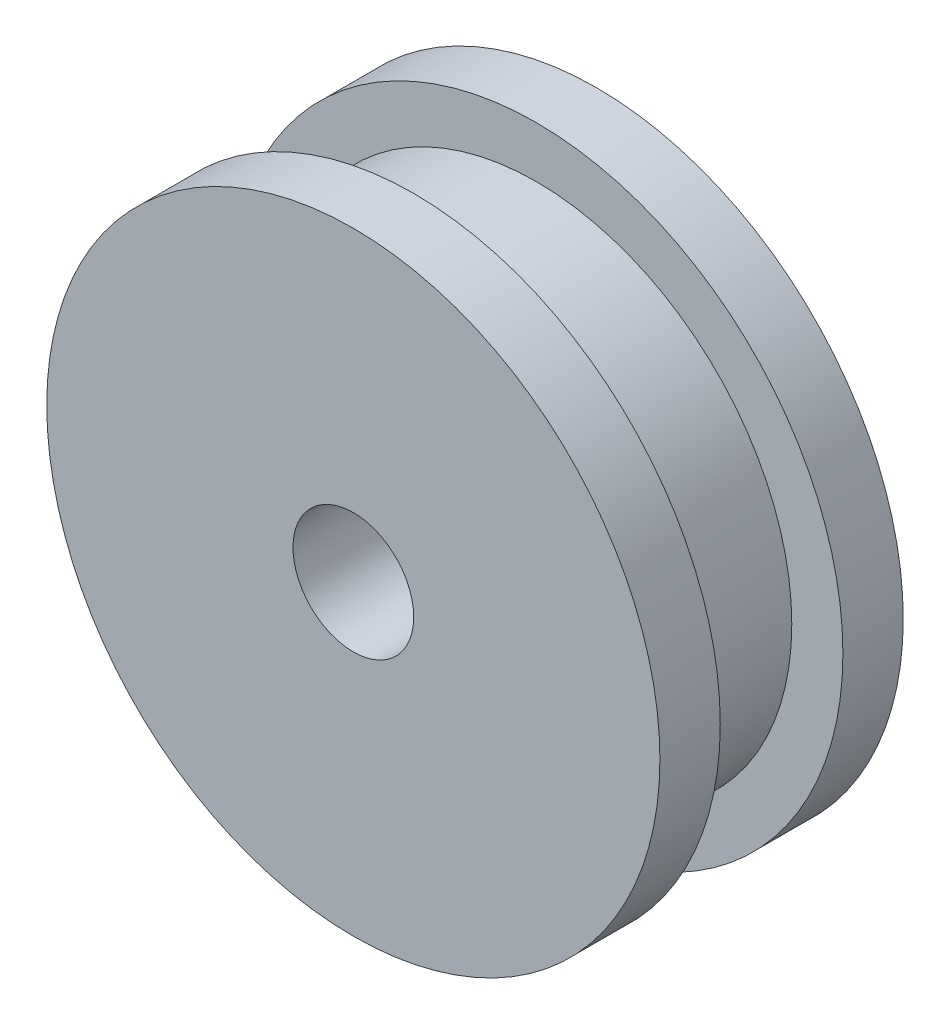
from build123d import *

# Parameters (mm, degrees)
SKETCH1_R           = 12.7
BOSS_EXTRUDE1_DEPTH = 3.048
SKETCH2_R           = 15.24
BOSS_EXTRUDE2_DEPTH = 3
SKETCH3_R           = 3
CUT_EXTRUDE1_DEPTH  = 25.606


with BuildPart() as part:
    # Sketch1 → Boss-Extrude1 (new body, symmetric)
    with BuildSketch(Plane.XY):
        Circle(SKETCH1_R)
    extrude(amount=BOSS_EXTRUDE1_DEPTH, both=True)

    # Sketch2 → Boss-Extrude2 (add)
    with BuildSketch(Plane.XY.offset(3.048)):
        Circle(SKETCH2_R)
    boss_extrude2 = extrude(amount=BOSS_EXTRUDE2_DEPTH)

    # Mirror1: Boss-Extrude2 across plane
    add(boss_extrude2.mirror(Plane.XY))

    # Sketch3 → Cut-Extrude1 (cut)
    with BuildSketch(Plane.XY.offset(6.048)):
        Circle(SKETCH3_R)
    extrude(amount=-CUT_EXTRUDE1_DEPTH, mode=Mode.SUBTRACT)


solid = part.part
